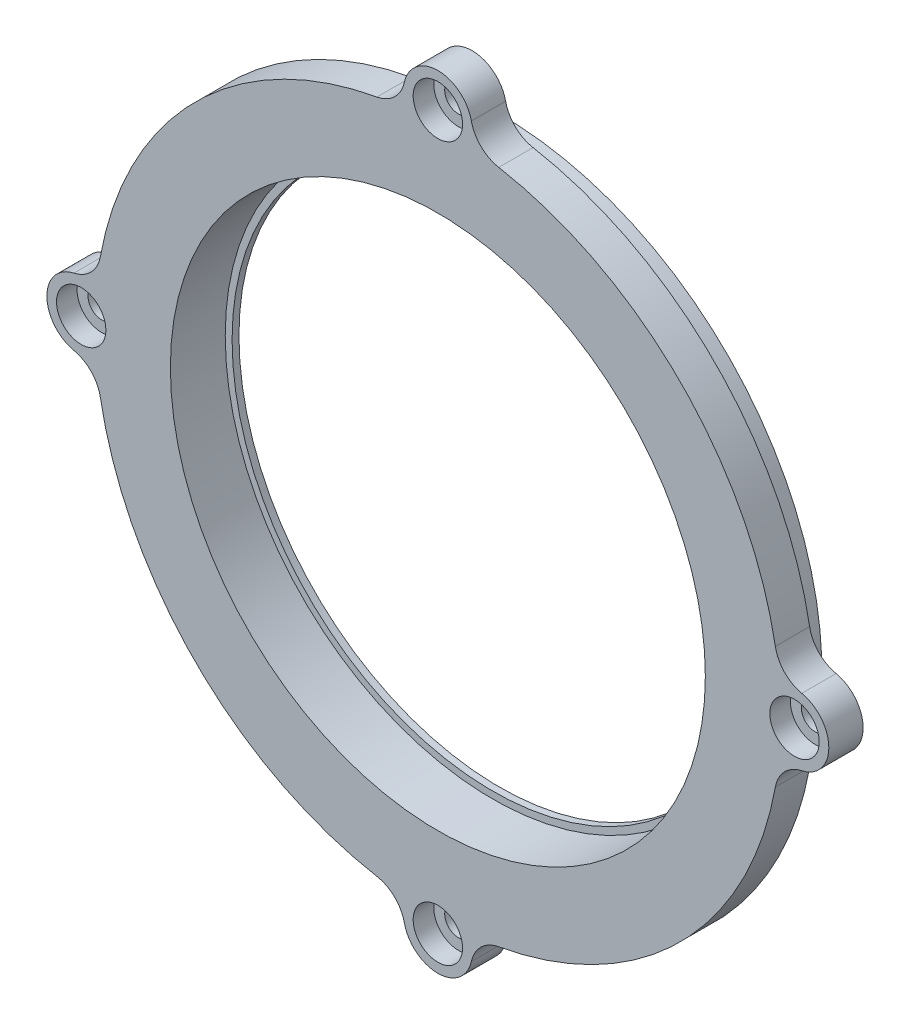
from build123d import *

# Parameters (mm, degrees)
SKETCH2_R           = 50
SKETCH2_R_2         = 39
BOSS_EXTRUDE1_DEPTH = 5
SKETCH3_R           = 47
SKETCH3_R_2         = 3
SKETCH3_R_3         = 39
BOSS_EXTRUDE2_DEPTH = 4
SKETCH4_R           = 39
SKETCH4_R_2         = 38
BOSS_EXTRUDE3_DEPTH = 1
SKETCH6_R           = 5
SKETCH6_R_2         = 2
BOSS_EXTRUDE4_DEPTH = 5
FILLET1_R           = 5
SKETCH7_R           = 3.6
CUT_EXTRUDE1_DEPTH  = 3
SKETCH8_R           = 3.15
CUT_EXTRUDE2_DEPTH  = 4


with BuildPart() as part:
    # Sketch2 → Boss-Extrude1 (new body)
    with BuildSketch(Plane.XY):
        Circle(SKETCH2_R)
        Circle(SKETCH2_R_2, mode=Mode.SUBTRACT)
    extrude(amount=BOSS_EXTRUDE1_DEPTH)

    # Sketch3 → Boss-Extrude2 (add)
    with BuildSketch(Plane(origin=(0, 0, 0), x_dir=(-1, 0, 0), z_dir=(0, 0, -1))):
        Circle(SKETCH3_R)
        with Locations((-43, 0)):
            Circle(SKETCH3_R_2, mode=Mode.SUBTRACT)
        Circle(SKETCH3_R_3, mode=Mode.SUBTRACT)
        with Locations((-32.939911054, 27.639867217)):
            Circle(SKETCH3_R_2, mode=Mode.SUBTRACT)
        with Locations((-7.46687164, 42.34673338)):
            Circle(SKETCH3_R_2, mode=Mode.SUBTRACT)
        with Locations((21.5, 37.239092363)):
            Circle(SKETCH3_R_2, mode=Mode.SUBTRACT)
        with Locations((40.406782694, 14.706866163)):
            Circle(SKETCH3_R_2, mode=Mode.SUBTRACT)
        with Locations((40.406782694, -14.706866163)):
            Circle(SKETCH3_R_2, mode=Mode.SUBTRACT)
        with Locations((21.5, -37.239092363)):
            Circle(SKETCH3_R_2, mode=Mode.SUBTRACT)
        with Locations((-7.46687164, -42.34673338)):
            Circle(SKETCH3_R_2, mode=Mode.SUBTRACT)
        with Locations((-32.939911054, -27.639867217)):
            Circle(SKETCH3_R_2, mode=Mode.SUBTRACT)
    extrude(amount=BOSS_EXTRUDE2_DEPTH)

    # Sketch4 → Boss-Extrude3 (add)
    with BuildSketch(Plane(origin=(0, 0, -4), x_dir=(-1, 0, 0), z_dir=(0, 0, -1))):
        Circle(SKETCH4_R)
        Circle(SKETCH4_R_2, mode=Mode.SUBTRACT)
    extrude(amount=-BOSS_EXTRUDE3_DEPTH)

    # Sketch6 → Boss-Extrude4 (add)
    with BuildSketch(Plane.XY.offset(5)):
        with Locations((52, 0)):
            Circle(SKETCH6_R)
        with Locations((52, 0)):
            Circle(SKETCH6_R_2, mode=Mode.SUBTRACT)
        with Locations((-52, 0)):
            Circle(SKETCH6_R)
        with Locations((-52, 0)):
            Circle(SKETCH6_R_2, mode=Mode.SUBTRACT)
        with Locations((0, 52)):
            Circle(SKETCH6_R)
        with Locations((0, 52)):
            Circle(SKETCH6_R_2, mode=Mode.SUBTRACT)
        with Locations((0, -52)):
            Circle(SKETCH6_R)
        with Locations((0, -52)):
            Circle(SKETCH6_R_2, mode=Mode.SUBTRACT)
    extrude(amount=-BOSS_EXTRUDE4_DEPTH)

    # Fillet1
    fillet1_edges = [part.edges().sort_by_distance(p)[0] for p in [
        (49.798076923, -4.489046086, 2.5),
        (49.798076923, 4.489046086, 2.5),
        (-49.798076923, 4.489046086, 2.5),
        (-49.798076923, -4.489046086, 2.5),
        (4.489046086, 49.798076923, 2.5),
        (-4.489046086, 49.798076923, 2.5),
        (-4.489046086, -49.798076923, 2.5),
        (4.489046086, -49.798076923, 2.5),
    ]]
    fillet(fillet1_edges, radius=FILLET1_R)

    # Sketch7 → Cut-Extrude1 (cut)
    with BuildSketch(Plane.XY.offset(5)):
        with Locations((52, 0)):
            Circle(SKETCH7_R)
        with Locations((0, 52)):
            Circle(SKETCH7_R)
        with Locations((-52, 0)):
            Circle(SKETCH7_R)
        with Locations((0, -52)):
            Circle(SKETCH7_R)
    extrude(amount=-CUT_EXTRUDE1_DEPTH, mode=Mode.SUBTRACT)

    # Sketch8 → Cut-Extrude2 (cut)
    with BuildSketch(Plane(origin=(0, 0, -4), x_dir=(-1, 0, 0), z_dir=(0, 0, -1))):
        with Locations((-32.939911054, 27.639867217)):
            Circle(SKETCH8_R)
        with Locations((-43, 0)):
            Circle(SKETCH8_R)
        with Locations((-7.46687164, 42.34673338)):
            Circle(SKETCH8_R)
        with Locations((21.5, 37.239092363)):
            Circle(SKETCH8_R)
        with Locations((40.406782694, 14.706866163)):
            Circle(SKETCH8_R)
        with Locations((40.406782694, -14.706866163)):
            Circle(SKETCH8_R)
        with Locations((21.5, -37.239092363)):
            Circle(SKETCH8_R)
        with Locations((-7.46687164, -42.34673338)):
            Circle(SKETCH8_R)
        with Locations((-32.939911054, -27.639867217)):
            Circle(SKETCH8_R)
    extrude(amount=-CUT_EXTRUDE2_DEPTH, mode=Mode.SUBTRACT)


solid = part.part
